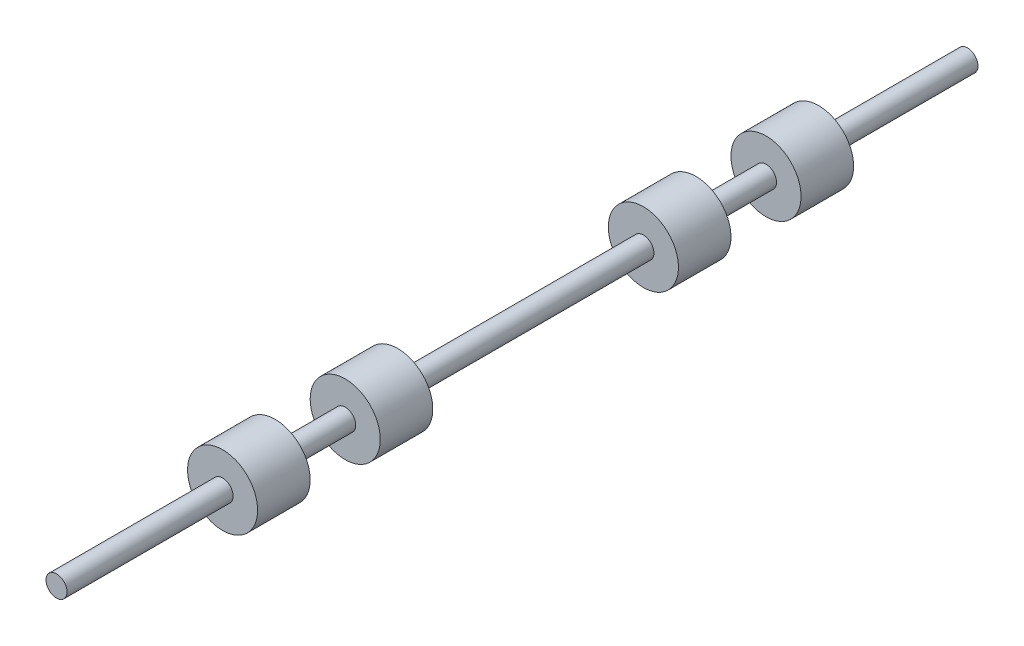
from build123d import *

# Parameters (mm, degrees)
SKETCH1_R           = 0.3
BOSS_EXTRUDE1_DEPTH = 26
SKETCH3_W           = 1
SKETCH3_H           = 1.5


with BuildPart() as part:
    # Sketch1 → Boss-Extrude1 (new body)
    with BuildSketch(Plane.XY):
        Circle(SKETCH1_R)
    extrude(amount=BOSS_EXTRUDE1_DEPTH)

    # Sketch3 → Revolve1 (revolve)
    with BuildSketch(Plane(origin=(0, 0, 0), x_dir=(1, 0, 0), z_dir=(0, 1, 0))):
        with Locations((0.5, -5)):
            Rectangle(SKETCH3_W, SKETCH3_H)
        with Locations((0.5, -8.5)):
            Rectangle(SKETCH3_W, SKETCH3_H)
        with Locations((0.5, -17.01)):
            Rectangle(SKETCH3_W, SKETCH3_H)
        with Locations((0.5, -20.51)):
            Rectangle(SKETCH3_W, SKETCH3_H)
    revolve(axis=Axis((0, 0, 0), (0, 0, 1)))


solid = part.part
